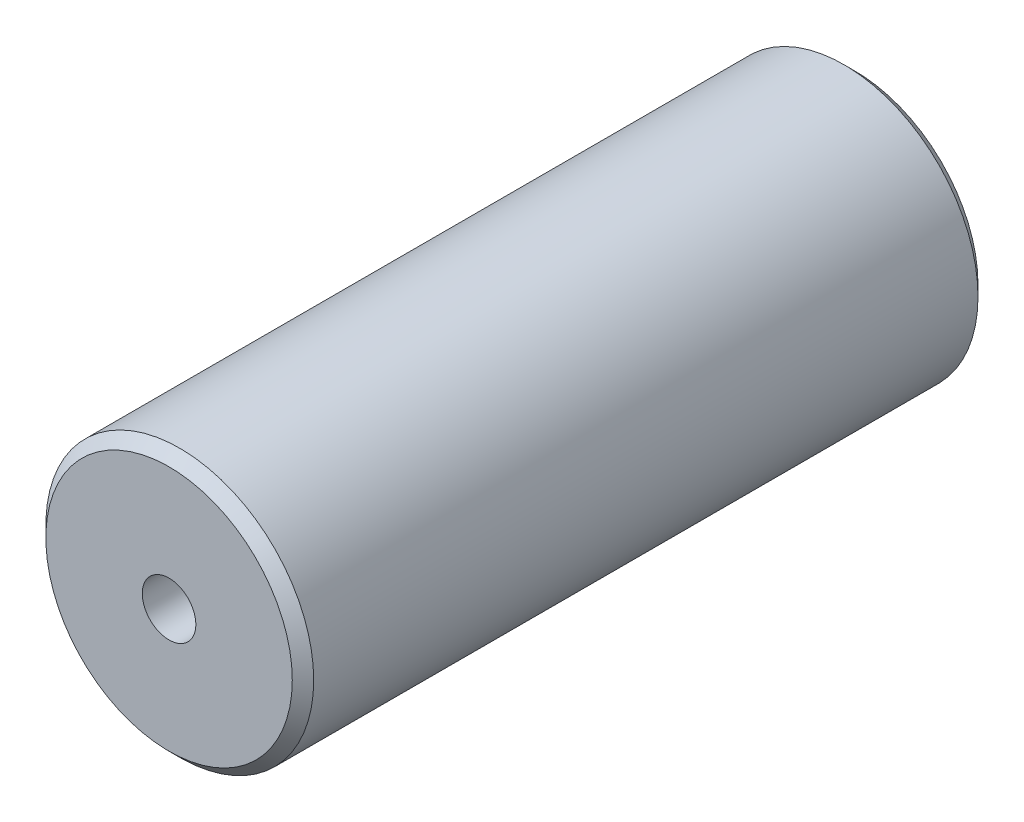
from build123d import *

# Parameters (mm, degrees)
SKETCH1_R           = 12.5
BOSS_EXTRUDE1_DEPTH = 32
CHAMFER1_SIZE       = 1


with BuildPart() as part:
    # Sketch1 → Boss-Extrude1 (new body, symmetric)
    with BuildSketch(Plane.XY):
        Circle(SKETCH1_R)
    extrude(amount=BOSS_EXTRUDE1_DEPTH, both=True)

    # Chamfer1
    chamfer1_edges = [part.edges().sort_by_distance(p)[0] for p in [
        (-12.5, 0, -32),
        (-12.5, 0, 32),
    ]]
    chamfer(chamfer1_edges, length=CHAMFER1_SIZE)

    # Sketch4 → Tap Drill for M6 Tap1 (revolve, cut)
    with BuildSketch(Plane(origin=(0, 0, 32), x_dir=(0, -1, 0), z_dir=(1, 0, 0))):
        Polygon((0, 0), (0, 14.502151548), (2.5, 13), (2.5, 0), align=None)
    tap_drill_for_m6_tap1 = revolve(axis=Axis((0, 0, 38.35), (0, 0, -1)), mode=Mode.SUBTRACT)

    # Mirror1: Tap Drill for M6 Tap1 across plane
    add(tap_drill_for_m6_tap1.mirror(Plane.XY), mode=Mode.SUBTRACT)


solid = part.part
